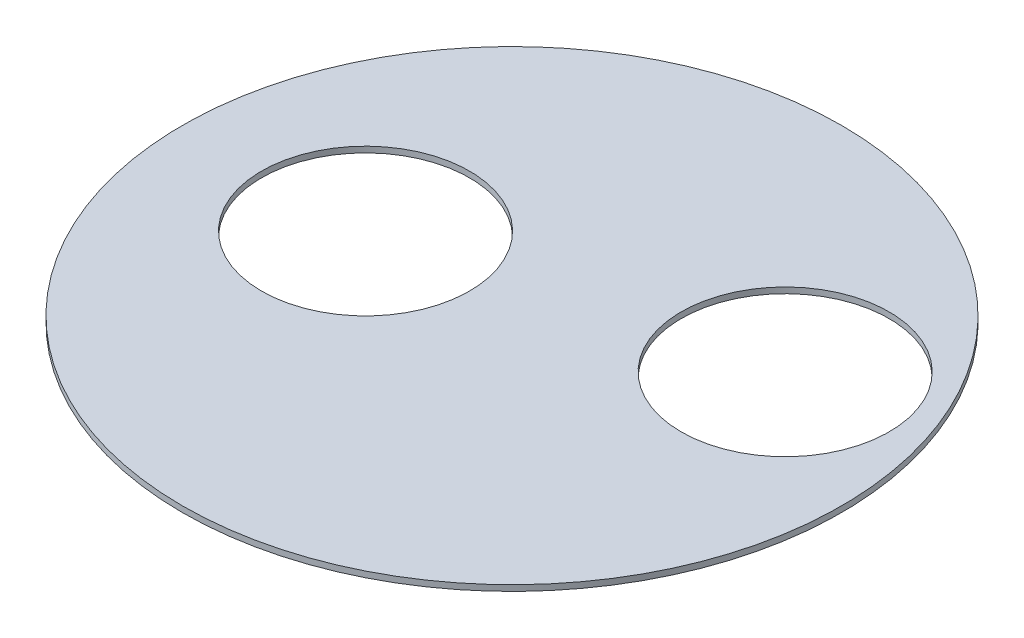
from build123d import *

# Parameters (mm, degrees)
IZIM1_R                     = 112.5
IZIM1_R_2                   = 35.5
Y_KSEKLIK_EKSTR_ZYON1_DEPTH = 2


with BuildPart() as part:
    # Çizim1 → Yükseklik-Ekstrüzyon1 (new body)
    with BuildSketch(Plane(origin=(0, 0, 0), x_dir=(1, 0, 0), z_dir=(0, 1, 0))):
        Circle(IZIM1_R)
        with Locations((63.245553203, 30)):
            Circle(IZIM1_R_2, mode=Mode.SUBTRACT)
        with Locations((-50, 0)):
            Circle(IZIM1_R_2, mode=Mode.SUBTRACT)
    extrude(amount=Y_KSEKLIK_EKSTR_ZYON1_DEPTH)


solid = part.part
